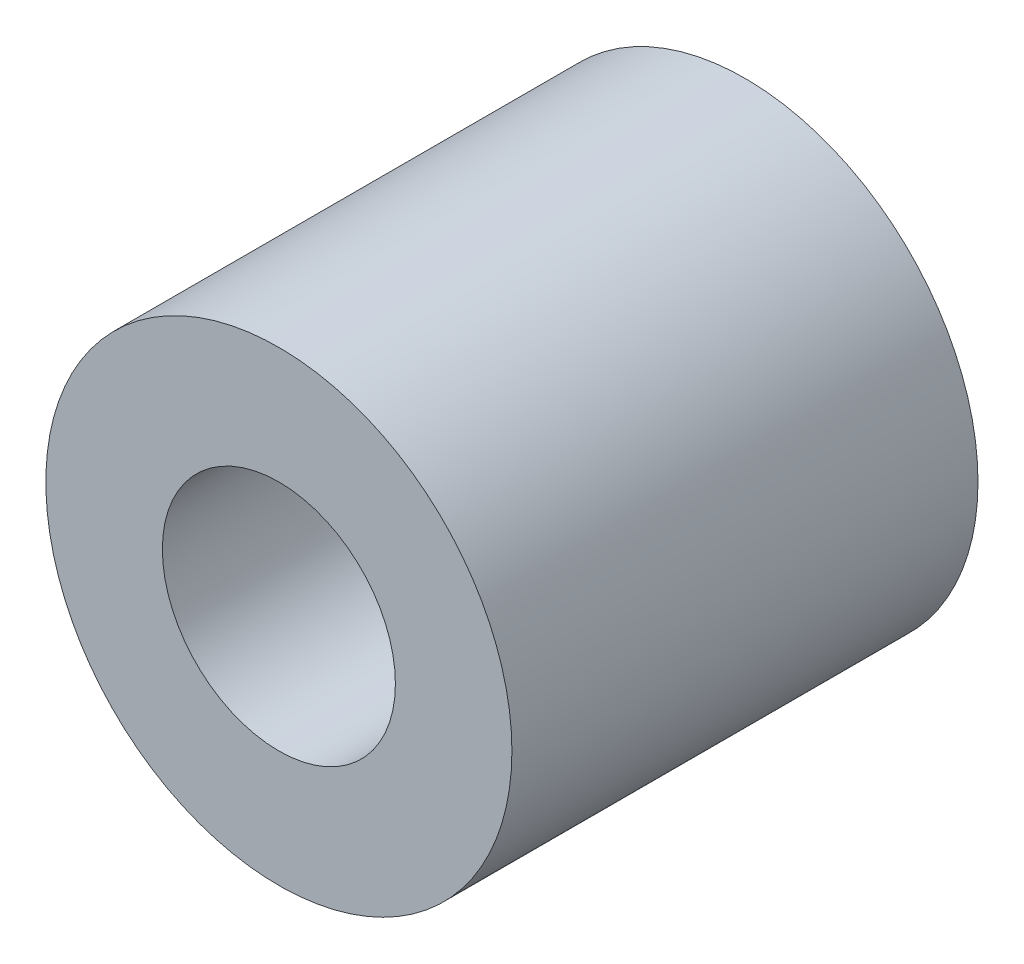
from build123d import *

# Parameters (mm, degrees)
SKETCH1_R           = 5
SKETCH1_R_2         = 2.5
BOSS_EXTRUDE1_DEPTH = 10


with BuildPart() as part:
    # Sketch1 → Boss-Extrude1 (new body)
    with BuildSketch(Plane.XY):
        Circle(SKETCH1_R)
        Circle(SKETCH1_R_2, mode=Mode.SUBTRACT)
    extrude(amount=BOSS_EXTRUDE1_DEPTH)


solid = part.part
